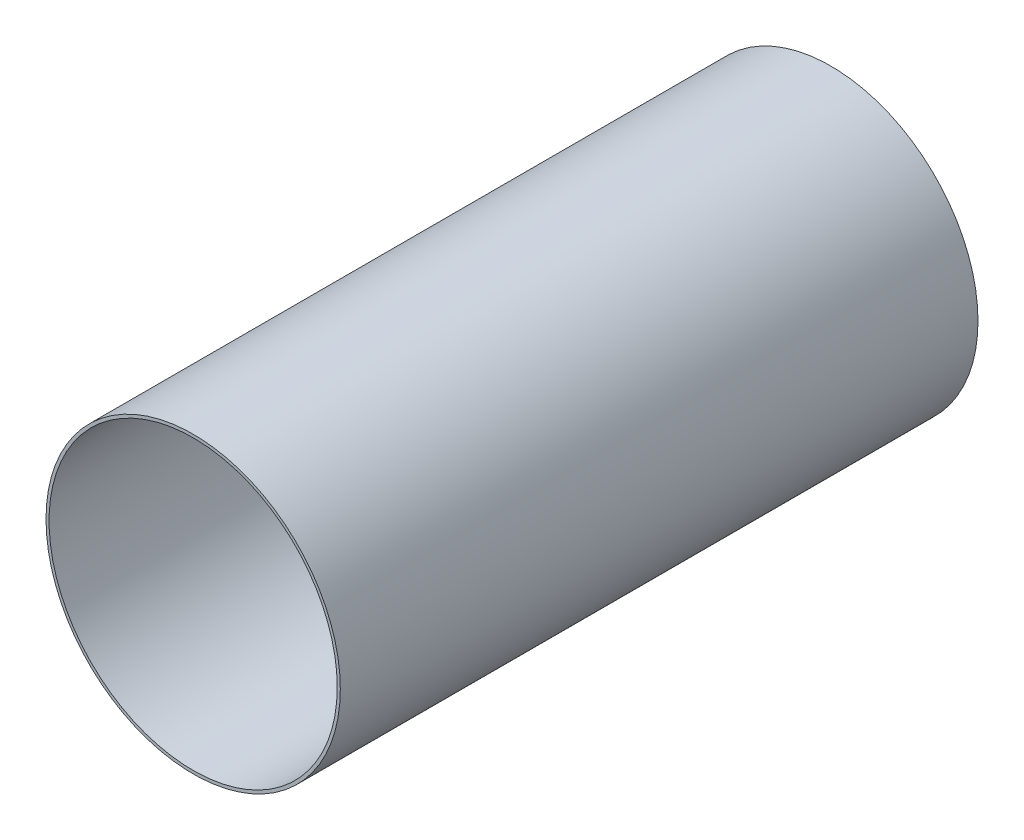
from build123d import *

# Parameters (mm, degrees)
SKETCH1_R           = 152.4
BOSS_EXTRUDE1_DEPTH = 660.4
SKETCH2_R           = 149.225
CUT_EXTRUDE1_DEPTH  = 660.4


with BuildPart() as part:
    # Sketch1 → Boss-Extrude1 (new body)
    with BuildSketch(Plane.XY):
        Circle(SKETCH1_R)
    extrude(amount=BOSS_EXTRUDE1_DEPTH)

    # Sketch2 → Cut-Extrude1 (cut)
    with BuildSketch(Plane.XY.offset(660.4)):
        Circle(SKETCH2_R)
    extrude(amount=-CUT_EXTRUDE1_DEPTH, mode=Mode.SUBTRACT)


solid = part.part
